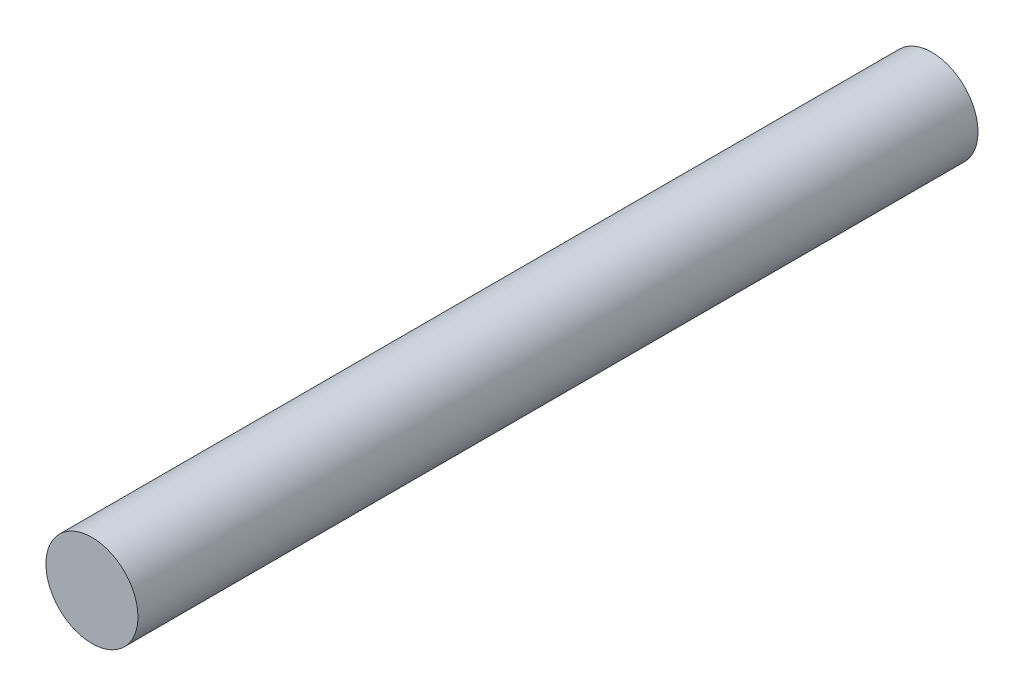
from build123d import *

# Parameters (mm, degrees)
SKETCH1_R           = 4
BOSS_EXTRUDE1_DEPTH = 60
SKETCH2_R           = 4
BOSS_EXTRUDE2_DEPTH = 13


with BuildPart() as part:
    # Sketch1 → Boss-Extrude1 (new body)
    with BuildSketch(Plane.XY):
        Circle(SKETCH1_R)
    extrude(amount=BOSS_EXTRUDE1_DEPTH)

    # Sketch2 → Boss-Extrude2 (add)
    with BuildSketch(Plane.XY):
        Circle(SKETCH2_R)
    extrude(amount=-BOSS_EXTRUDE2_DEPTH)


solid = part.part
